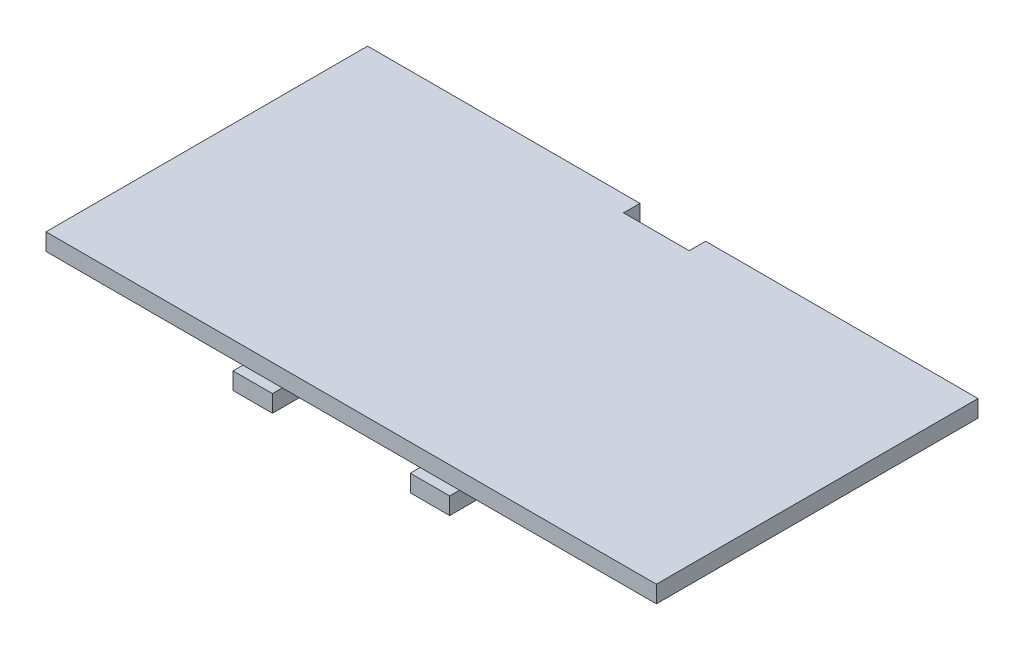
from build123d import *

# Parameters (mm, degrees)
SKETCH1_W           = 93
SKETCH1_H           = 49
BOSS_EXTRUDE1_DEPTH = 2.6
SKETCH2_W           = 10
SKETCH2_H           = 2.5
CUT_EXTRUDE1_DEPTH  = 2.6
BOSS_EXTRUDE2_DEPTH = 2.6


with BuildPart() as part:
    # Sketch1 → Boss-Extrude1 (new body)
    with BuildSketch(Plane(origin=(0, 0, 0), x_dir=(1, 0, 0), z_dir=(0, 1, 0))):
        Rectangle(SKETCH1_W, SKETCH1_H)
    extrude(amount=BOSS_EXTRUDE1_DEPTH)

    # Sketch2 → Cut-Extrude1 (cut)
    with BuildSketch(Plane(origin=(0, 2.6, 0), x_dir=(1, 0, 0), z_dir=(0, 1, 0))):
        with Locations((0, 23.25)):
            Rectangle(SKETCH2_W, SKETCH2_H)
    extrude(amount=-CUT_EXTRUDE1_DEPTH, mode=Mode.SUBTRACT)

    # Sketch3 → Boss-Extrude2 (add)
    with BuildSketch(Plane.XZ):
        Polygon((-16.5, 23), (-16.5, 26), (-10.5, 26), (-10.5, 23), (-10.5, 21.5), (-16.5, 21.5), align=None)
        Polygon((10.5, 23), (10.5, 26), (16.5, 26), (16.5, 23), (16.5, 21.5), (10.5, 21.5), align=None)
    extrude(amount=BOSS_EXTRUDE2_DEPTH)


solid = part.part
